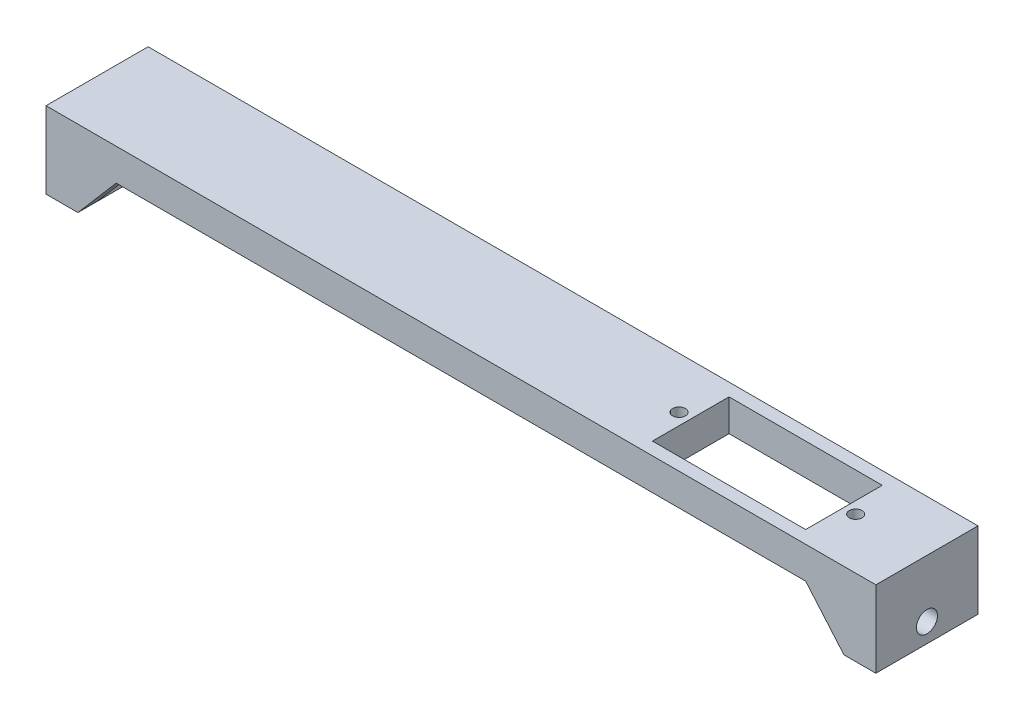
from build123d import *

# Parameters (mm, degrees)
EXTRUDE_2_DEPTH          = 16
SKETCH_3_R               = 1.65
CUT_EXTRUDE_1_DEPTH      = 126
CUT_EXTRUDE_1_DEPTH_BACK = 6
EXTRUDE_3_DEPTH          = 3
MIRROR_2_COPY_1_DEPTH    = 3
SKETCH_7_W               = 24
SKETCH_7_H               = 12
CUT_EXTRUDE_2_DEPTH      = 5
SKETCH_10_R              = 1
CUT_EXTRUDE_3_DEPTH      = 5


with BuildPart() as part:
    # 草图1 → 凸台-拉伸2 (new body)
    with BuildSketch(Plane.XY):
        Polygon((-65, 0), (65, 0), (65, -12), (60, -12), (60, -5), (-60, -5), (-60, -12), (-65, -12), align=None)
    extrude(amount=EXTRUDE_2_DEPTH)

    # 草图3 → 切除-拉伸1 (cut, two sides)
    with BuildSketch(Plane(origin=(-60, 0, 0), x_dir=(0, 0, -1), z_dir=(1, 0, 0))) as cut_extrude_1_sk:
        with Locations((-8, -9)):
            Circle(SKETCH_3_R)
    extrude(amount=CUT_EXTRUDE_1_DEPTH, mode=Mode.SUBTRACT)
    extrude(cut_extrude_1_sk.sketch, amount=-CUT_EXTRUDE_1_DEPTH_BACK, mode=Mode.SUBTRACT)

    # 草图4 → 凸台-拉伸3 (add)
    with BuildSketch(Plane(origin=(0, 0, 0), x_dir=(-1, 0, 0), z_dir=(0, 0, -1))):
        Polygon((54, -5), (60, -12), (60, -5), align=None)
    extrude_3 = extrude(amount=-EXTRUDE_3_DEPTH)

    # 镜向1: 凸台-拉伸3 across plane
    add(extrude_3.mirror(Plane.XY.offset(8)))

    # 镜向2: 凸台-拉伸3 across plane
    add(extrude_3.mirror(Plane(origin=(0, 0, 0), x_dir=(0, 0, 1), z_dir=(1, 0, 0))))

    # 镜向2 copy 1 sketch → 镜向2 copy 1 (add)
    with BuildSketch(Plane.XY.offset(16)):
        Polygon((54, -5), (60, -12), (60, -5), align=None)
    extrude(amount=-MIRROR_2_COPY_1_DEPTH)

    # 草图7 → 切除-拉伸2 (cut)
    with BuildSketch(Plane.XZ.offset(5)):
        with Locations((40, 8)):
            Rectangle(SKETCH_7_W, SKETCH_7_H)
    extrude(amount=-CUT_EXTRUDE_2_DEPTH, mode=Mode.SUBTRACT)

    # 草图10 → 切除-拉伸3 (cut)
    with BuildSketch(Plane.XZ.offset(5)):
        with Locations((53.835, 8)):
            Circle(SKETCH_10_R)
        with Locations((26.165, 8)):
            Circle(SKETCH_10_R)
    extrude(amount=-CUT_EXTRUDE_3_DEPTH, mode=Mode.SUBTRACT)


solid = part.part
